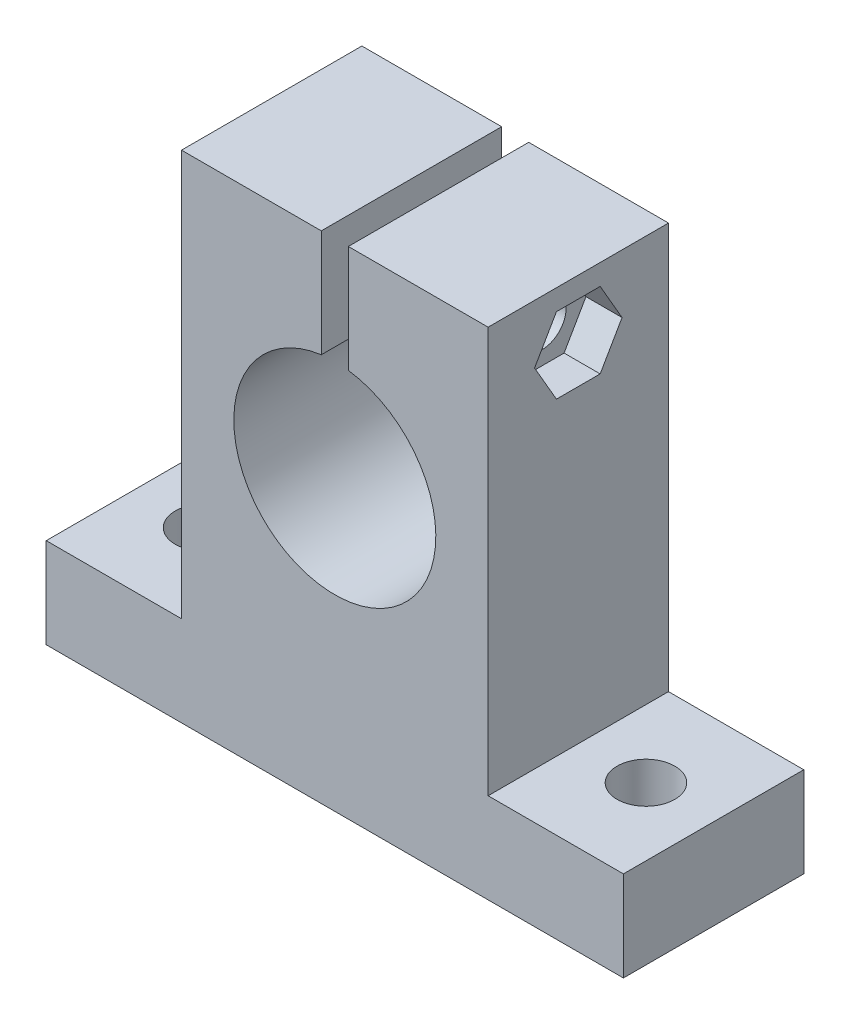
from build123d import *

# Parameters (mm, degrees)
EXTRUDE_1_DEPTH     = 20
SKETCH_2_R          = 2.65
CUT_EXTRUDE_1_DEPTH = 20
CUT_EXTRUDE_2_DEPTH = 4
SKETCH_5_R          = 3.2
CUT_EXTRUDE_3_DEPTH = 56


with BuildPart() as part:
    # 草图1 → 凸台-拉伸1 (new body)
    with BuildSketch(Plane.XY):
        with BuildLine():
            Line((17, -0.197530864), (1.5, -0.197530864))
            Line((1.5, -0.197530864), (1.5, -12.098431802))
            ThreePointArc((1.5, -12.098431802), (0, -34.397530864), (-1.5, -12.098431802))
            Line((-1.5, -12.098431802), (-1.5, -0.197530864))
            Line((-1.5, -0.197530864), (-17, -0.197530864))
            Line((-17, -0.197530864), (-17, -45.197530864))
            Line((-17, -45.197530864), (-32, -45.197530864))
            Line((-32, -45.197530864), (-32, -55.197530864))
            Line((-32, -55.197530864), (32, -55.197530864))
            Line((32, -55.197530864), (32, -45.197530864))
            Line((32, -45.197530864), (17, -45.197530864))
            Line((17, -45.197530864), (17, -0.197530864))
        make_face()
    extrude(amount=EXTRUDE_1_DEPTH)

    # 草图2 → 切除-拉伸1 (cut, symmetric)
    with BuildSketch(Plane(origin=(0, 0, 0), x_dir=(0, 0, -1), z_dir=(1, 0, 0))):
        with Locations((-10, -6.697530864)):
            Circle(SKETCH_2_R)
    extrude(amount=CUT_EXTRUDE_1_DEPTH, both=True, mode=Mode.SUBTRACT)

    # 草图3 → 切除-拉伸2 (cut)
    with BuildSketch(Plane(origin=(17, 0, 0), x_dir=(0, 0, -1), z_dir=(1, 0, 0))):
        Polygon((-5.150756421, -6.697530864), (-7.575378211, -2.497962736), (-12.424621789, -2.497962736), (-14.849243579, -6.697530864), (-12.424621789, -10.897098992), (-7.575378211, -10.897098992), align=None)
    extrude(amount=-CUT_EXTRUDE_2_DEPTH, mode=Mode.SUBTRACT)

    # 草图5 → 切除-拉伸3 (cut, through all)
    with BuildSketch(Plane.XZ.offset(55.197530864)):
        with Locations((-24.5, 10)):
            Circle(SKETCH_5_R)
        with Locations((24.5, 10)):
            Circle(SKETCH_5_R)
    extrude(amount=-CUT_EXTRUDE_3_DEPTH, mode=Mode.SUBTRACT)


solid = part.part
